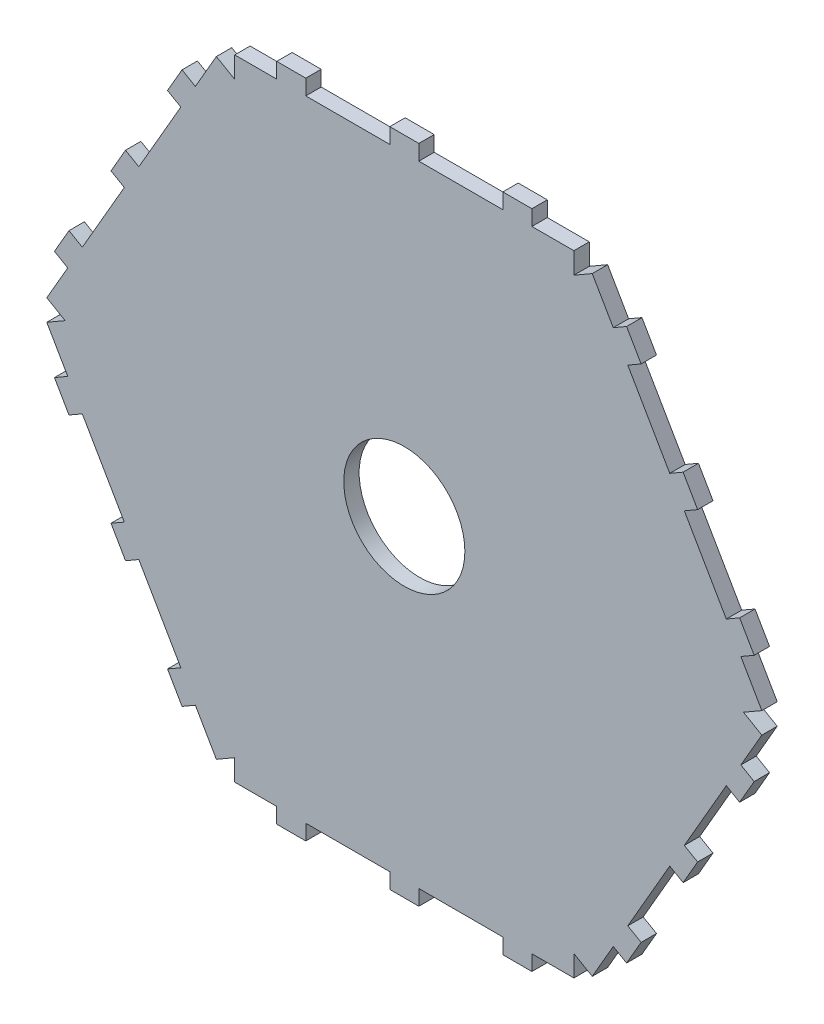
from build123d import *

# Parameters (mm, degrees)
SKETCH2_R           = 12.5
BOSS_EXTRUDE1_DEPTH = 1.5875


with BuildPart() as part:
    # Sketch2 → Boss-Extrude1 (new body, symmetric)
    with BuildSketch(Plane.XY):
        Polygon((-35, 65), (-35, 60.621778265), (-38.791651246, 62.810889132), (-43.124984579, 55.305335633), (-45.874615236, 56.892835633), (-48.874615236, 51.69668321), (-46.124984579, 50.10918321), (-54.791651246, 35.098076211), (-57.541281903, 36.685576211), (-60.541281903, 31.489423789), (-57.791651246, 29.901923789), (-66.458317913, 14.89081679), (-69.20794857, 16.47831679), (-72.20794857, 11.282164367), (-69.458317913, 9.694664367), (-73.791651246, 2.189110868), (-70, 0), (-73.791651246, -2.189110868), (-69.458317913, -9.694664367), (-72.20794857, -11.282164367), (-69.20794857, -16.47831679), (-66.458317913, -14.89081679), (-57.791651246, -29.901923789), (-60.541281903, -31.489423789), (-57.541281903, -36.685576211), (-54.791651246, -35.098076211), (-46.124984579, -50.10918321), (-48.874615236, -51.69668321), (-45.874615236, -56.892835633), (-43.124984579, -55.305335633), (-38.791651246, -62.810889132), (-35, -60.621778265), (-35, -65), (-26.333333333, -65), (-26.333333333, -68.175), (-20.333333333, -68.175), (-20.333333333, -65), (-3, -65), (-3, -68.175), (3, -68.175), (3, -65), (20.333333333, -65), (20.333333333, -68.175), (26.333333333, -68.175), (26.333333333, -65), (35, -65), (35, -60.621778265), (38.791651246, -62.810889132), (43.124984579, -55.305335633), (45.874615236, -56.892835633), (48.874615236, -51.69668321), (46.124984579, -50.10918321), (54.791651246, -35.098076211), (57.541281903, -36.685576211), (60.541281903, -31.489423789), (57.791651246, -29.901923789), (66.458317913, -14.89081679), (69.20794857, -16.47831679), (72.20794857, -11.282164367), (69.458317913, -9.694664367), (73.791651246, -2.189110868), (70, 0), (73.791651246, 2.189110868), (69.458317913, 9.694664367), (72.20794857, 11.282164367), (69.20794857, 16.47831679), (66.458317913, 14.89081679), (57.791651246, 29.901923789), (60.541281903, 31.489423789), (57.541281903, 36.685576211), (54.791651246, 35.098076211), (46.124984579, 50.10918321), (48.874615236, 51.69668321), (45.874615236, 56.892835633), (43.124984579, 55.305335633), (38.791651246, 62.810889132), (35, 60.621778265), (35, 65), (26.333333333, 65), (26.333333333, 68.175), (20.333333333, 68.175), (20.333333333, 65), (3, 65), (3, 68.175), (-3, 68.175), (-3, 65), (-20.333333333, 65), (-20.333333333, 68.175), (-26.333333333, 68.175), (-26.333333333, 65), align=None)
        Circle(SKETCH2_R, mode=Mode.SUBTRACT)
    extrude(amount=BOSS_EXTRUDE1_DEPTH, both=True)


solid = part.part
